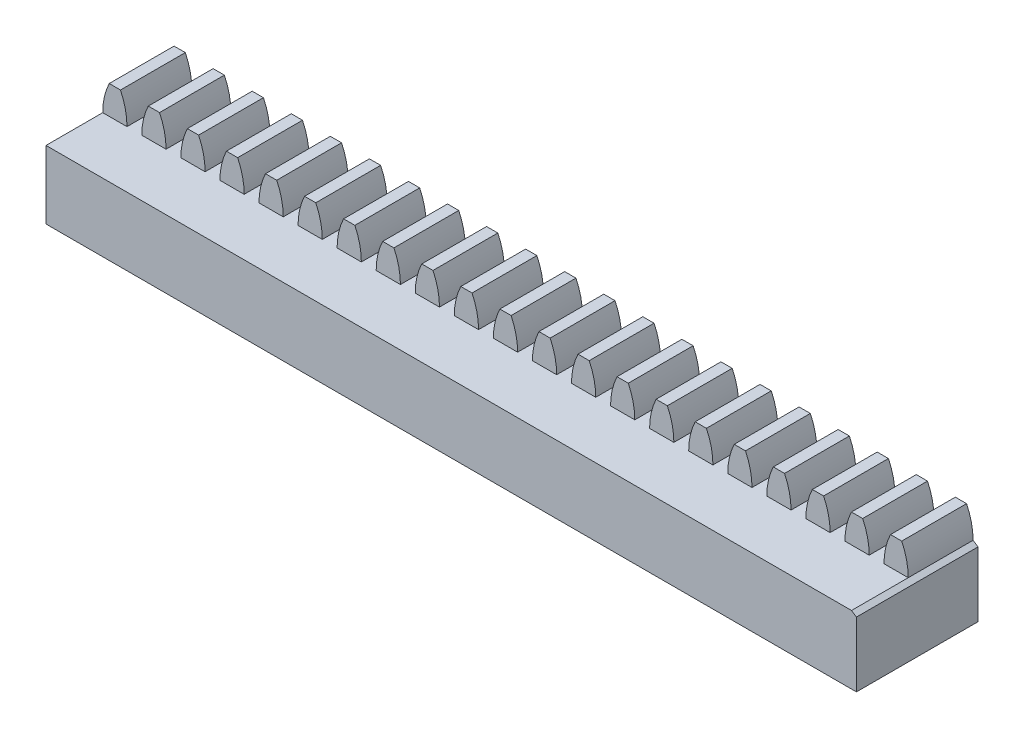
from build123d import *

# Parameters (mm, degrees)
RESSALTO_EXTRUS_O1_DEPTH      = 2
RESSALTO_EXTRUS_O1_2_DEPTH    = 2
RESSALTO_EXTRUS_O1_3_DEPTH    = 2
RESSALTO_EXTRUS_O1_4_DEPTH    = 2
RESSALTO_EXTRUS_O1_5_DEPTH    = 2
RESSALTO_EXTRUS_O1_6_DEPTH    = 2
RESSALTO_EXTRUS_O1_7_DEPTH    = 2
RESSALTO_EXTRUS_O1_8_DEPTH    = 2
RESSALTO_EXTRUS_O1_9_DEPTH    = 2
RESSALTO_EXTRUS_O1_10_DEPTH   = 2
RESSALTO_EXTRUS_O1_11_DEPTH   = 2
RESSALTO_EXTRUS_O1_12_DEPTH   = 2
RESSALTO_EXTRUS_O1_13_DEPTH   = 2
RESSALTO_EXTRUS_O1_14_DEPTH   = 2
RESSALTO_EXTRUS_O1_15_DEPTH   = 2
RESSALTO_EXTRUS_O1_16_DEPTH   = 2
RESSALTO_EXTRUS_O1_17_DEPTH   = 2
RESSALTO_EXTRUS_O1_18_DEPTH   = 2
RESSALTO_EXTRUS_O1_19_DEPTH   = 2
RESSALTO_EXTRUS_O1_20_DEPTH   = 2
RESSALTO_EXTRUS_O1_21_DEPTH   = 2
RESSALTO_EXTRUS_O2_DEPTH      = 5.5
RESSALTO_EXTRUS_O2_DEPTH_BACK = 2


with BuildPart() as part:
    # Esboço1 → Ressalto-extrusão1 (new, symmetric)
    with BuildSketch(Plane.XY):
        with BuildLine():
            Line((-1.017526261, 4.529689969), (-1.711247382, 4.529689969))
            ThreePointArc((-1.711247382, 4.529689969), (-2.010696446, 3.673045524), (-2.112202188, 2.771266155))
            Line((-2.112202188, 2.771266155), (-0.616571456, 2.771266155))
            ThreePointArc((-0.616571456, 2.771266155), (-0.718077198, 3.673045524), (-1.017526261, 4.529689969))
        make_face()
    extrude(amount=RESSALTO_EXTRUS_O1_DEPTH, both=True)



with BuildPart() as body_2:
    # Esboço1 → Ressalto-extrus_o1 2 (new, symmetric)
    with BuildSketch(Plane.XY):
        with BuildLine():
            ThreePointArc((0.698752618, 4.529689969), (0.399303554, 3.673045524), (0.297797812, 2.771266155))
            Line((0.297797812, 2.771266155), (1.793428544, 2.771266155))
            ThreePointArc((1.793428544, 2.771266155), (1.691922802, 3.673045524), (1.392473739, 4.529689969))
            Line((1.392473739, 4.529689969), (0.698752618, 4.529689969))
        make_face()
    extrude(amount=RESSALTO_EXTRUS_O1_2_DEPTH, both=True)


with BuildPart() as body_3:
    # Esboço1 → Ressalto-extrus_o1 3 (new, symmetric)
    with BuildSketch(Plane.XY):
        with BuildLine():
            ThreePointArc((3.108752618, 4.529689969), (2.809303554, 3.673045524), (2.707797812, 2.771266155))
            Line((2.707797812, 2.771266155), (4.203428544, 2.771266155))
            ThreePointArc((4.203428544, 2.771266155), (4.101922802, 3.673045524), (3.802473739, 4.529689969))
            Line((3.802473739, 4.529689969), (3.108752618, 4.529689969))
        make_face()
    extrude(amount=RESSALTO_EXTRUS_O1_3_DEPTH, both=True)


with BuildPart() as body_4:
    # Esboço1 → Ressalto-extrus_o1 4 (new, symmetric)
    with BuildSketch(Plane.XY):
        with BuildLine():
            Line((46.087797812, 2.771266155), (47.583428544, 2.771266155))
            ThreePointArc((47.583428544, 2.771266155), (47.481922802, 3.673045524), (47.182473739, 4.529689969))
            Line((47.182473739, 4.529689969), (46.488752618, 4.529689969))
            ThreePointArc((46.488752618, 4.529689969), (46.189303554, 3.673045524), (46.087797812, 2.771266155))
        make_face()
    extrude(amount=RESSALTO_EXTRUS_O1_4_DEPTH, both=True)


with BuildPart() as body_5:
    # Esboço1 → Ressalto-extrus_o1 5 (new, symmetric)
    with BuildSketch(Plane.XY):
        with BuildLine():
            ThreePointArc((5.518752618, 4.529689969), (5.219303554, 3.673045524), (5.117797812, 2.771266155))
            Line((5.117797812, 2.771266155), (6.613428544, 2.771266155))
            ThreePointArc((6.613428544, 2.771266155), (6.511922802, 3.673045524), (6.212473739, 4.529689969))
            Line((6.212473739, 4.529689969), (5.518752618, 4.529689969))
        make_face()
    extrude(amount=RESSALTO_EXTRUS_O1_5_DEPTH, both=True)


with BuildPart() as body_6:
    # Esboço1 → Ressalto-extrus_o1 6 (new, symmetric)
    with BuildSketch(Plane.XY):
        with BuildLine():
            Line((43.677797812, 2.771266155), (45.173428544, 2.771266155))
            ThreePointArc((45.173428544, 2.771266155), (45.071922802, 3.673045524), (44.772473739, 4.529689969))
            Line((44.772473739, 4.529689969), (44.078752618, 4.529689969))
            ThreePointArc((44.078752618, 4.529689969), (43.779303554, 3.673045524), (43.677797812, 2.771266155))
        make_face()
    extrude(amount=RESSALTO_EXTRUS_O1_6_DEPTH, both=True)


with BuildPart() as body_7:
    # Esboço1 → Ressalto-extrus_o1 7 (new, symmetric)
    with BuildSketch(Plane.XY):
        with BuildLine():
            ThreePointArc((7.928752618, 4.529689969), (7.629303554, 3.673045524), (7.527797812, 2.771266155))
            Line((7.527797812, 2.771266155), (9.023428544, 2.771266155))
            ThreePointArc((9.023428544, 2.771266155), (8.921922802, 3.673045524), (8.622473739, 4.529689969))
            Line((8.622473739, 4.529689969), (7.928752618, 4.529689969))
        make_face()
    extrude(amount=RESSALTO_EXTRUS_O1_7_DEPTH, both=True)


with BuildPart() as body_8:
    # Esboço1 → Ressalto-extrus_o1 8 (new, symmetric)
    with BuildSketch(Plane.XY):
        with BuildLine():
            Line((41.267797812, 2.771266155), (42.763428544, 2.771266155))
            ThreePointArc((42.763428544, 2.771266155), (42.661922802, 3.673045524), (42.362473739, 4.529689969))
            Line((42.362473739, 4.529689969), (41.668752618, 4.529689969))
            ThreePointArc((41.668752618, 4.529689969), (41.369303554, 3.673045524), (41.267797812, 2.771266155))
        make_face()
    extrude(amount=RESSALTO_EXTRUS_O1_8_DEPTH, both=True)


with BuildPart() as body_9:
    # Esboço1 → Ressalto-extrus_o1 9 (new, symmetric)
    with BuildSketch(Plane.XY):
        with BuildLine():
            ThreePointArc((10.338752618, 4.529689969), (10.039303554, 3.673045524), (9.937797812, 2.771266155))
            Line((9.937797812, 2.771266155), (11.433428544, 2.771266155))
            ThreePointArc((11.433428544, 2.771266155), (11.331922802, 3.673045524), (11.032473739, 4.529689969))
            Line((11.032473739, 4.529689969), (10.338752618, 4.529689969))
        make_face()
    extrude(amount=RESSALTO_EXTRUS_O1_9_DEPTH, both=True)


with BuildPart() as body_10:
    # Esboço1 → Ressalto-extrus_o1 10 (new, symmetric)
    with BuildSketch(Plane.XY):
        with BuildLine():
            Line((38.857797812, 2.771266155), (40.353428544, 2.771266155))
            ThreePointArc((40.353428544, 2.771266155), (40.251922802, 3.673045524), (39.952473739, 4.529689969))
            Line((39.952473739, 4.529689969), (39.258752618, 4.529689969))
            ThreePointArc((39.258752618, 4.529689969), (38.959303554, 3.673045524), (38.857797812, 2.771266155))
        make_face()
    extrude(amount=RESSALTO_EXTRUS_O1_10_DEPTH, both=True)


with BuildPart() as body_11:
    # Esboço1 → Ressalto-extrus_o1 11 (new, symmetric)
    with BuildSketch(Plane.XY):
        with BuildLine():
            ThreePointArc((12.748752618, 4.529689969), (12.449303554, 3.673045524), (12.347797812, 2.771266155))
            Line((12.347797812, 2.771266155), (13.843428544, 2.771266155))
            ThreePointArc((13.843428544, 2.771266155), (13.741922802, 3.673045524), (13.442473739, 4.529689969))
            Line((13.442473739, 4.529689969), (12.748752618, 4.529689969))
        make_face()
    extrude(amount=RESSALTO_EXTRUS_O1_11_DEPTH, both=True)


with BuildPart() as body_12:
    # Esboço1 → Ressalto-extrus_o1 12 (new, symmetric)
    with BuildSketch(Plane.XY):
        with BuildLine():
            Line((36.447797812, 2.771266155), (37.943428544, 2.771266155))
            ThreePointArc((37.943428544, 2.771266155), (37.841922802, 3.673045524), (37.542473739, 4.529689969))
            Line((37.542473739, 4.529689969), (36.848752618, 4.529689969))
            ThreePointArc((36.848752618, 4.529689969), (36.549303554, 3.673045524), (36.447797812, 2.771266155))
        make_face()
    extrude(amount=RESSALTO_EXTRUS_O1_12_DEPTH, both=True)


with BuildPart() as body_13:
    # Esboço1 → Ressalto-extrus_o1 13 (new, symmetric)
    with BuildSketch(Plane.XY):
        with BuildLine():
            ThreePointArc((15.158752618, 4.529689969), (14.859303554, 3.673045524), (14.757797812, 2.771266155))
            Line((14.757797812, 2.771266155), (16.253428544, 2.771266155))
            ThreePointArc((16.253428544, 2.771266155), (16.151922802, 3.673045524), (15.852473739, 4.529689969))
            Line((15.852473739, 4.529689969), (15.158752618, 4.529689969))
        make_face()
    extrude(amount=RESSALTO_EXTRUS_O1_13_DEPTH, both=True)


with BuildPart() as body_14:
    # Esboço1 → Ressalto-extrus_o1 14 (new, symmetric)
    with BuildSketch(Plane.XY):
        with BuildLine():
            Line((34.037797812, 2.771266155), (35.533428544, 2.771266155))
            ThreePointArc((35.533428544, 2.771266155), (35.431922802, 3.673045524), (35.132473739, 4.529689969))
            Line((35.132473739, 4.529689969), (34.438752618, 4.529689969))
            ThreePointArc((34.438752618, 4.529689969), (34.139303554, 3.673045524), (34.037797812, 2.771266155))
        make_face()
    extrude(amount=RESSALTO_EXTRUS_O1_14_DEPTH, both=True)


with BuildPart() as body_15:
    # Esboço1 → Ressalto-extrus_o1 15 (new, symmetric)
    with BuildSketch(Plane.XY):
        with BuildLine():
            ThreePointArc((17.568752618, 4.529689969), (17.269303554, 3.673045524), (17.167797812, 2.771266155))
            Line((17.167797812, 2.771266155), (18.663428544, 2.771266155))
            ThreePointArc((18.663428544, 2.771266155), (18.561922802, 3.673045524), (18.262473739, 4.529689969))
            Line((18.262473739, 4.529689969), (17.568752618, 4.529689969))
        make_face()
    extrude(amount=RESSALTO_EXTRUS_O1_15_DEPTH, both=True)


with BuildPart() as body_16:
    # Esboço1 → Ressalto-extrus_o1 16 (new, symmetric)
    with BuildSketch(Plane.XY):
        with BuildLine():
            Line((31.627797812, 2.771266155), (33.123428544, 2.771266155))
            ThreePointArc((33.123428544, 2.771266155), (33.021922802, 3.673045524), (32.722473739, 4.529689969))
            Line((32.722473739, 4.529689969), (32.028752618, 4.529689969))
            ThreePointArc((32.028752618, 4.529689969), (31.729303554, 3.673045524), (31.627797812, 2.771266155))
        make_face()
    extrude(amount=RESSALTO_EXTRUS_O1_16_DEPTH, both=True)


with BuildPart() as body_17:
    # Esboço1 → Ressalto-extrus_o1 17 (new, symmetric)
    with BuildSketch(Plane.XY):
        with BuildLine():
            ThreePointArc((19.978752618, 4.529689969), (19.679303554, 3.673045524), (19.577797812, 2.771266155))
            Line((19.577797812, 2.771266155), (21.073428544, 2.771266155))
            ThreePointArc((21.073428544, 2.771266155), (20.971922802, 3.673045524), (20.672473739, 4.529689969))
            Line((20.672473739, 4.529689969), (19.978752618, 4.529689969))
        make_face()
    extrude(amount=RESSALTO_EXTRUS_O1_17_DEPTH, both=True)


with BuildPart() as body_18:
    # Esboço1 → Ressalto-extrus_o1 18 (new, symmetric)
    with BuildSketch(Plane.XY):
        with BuildLine():
            Line((29.217797812, 2.771266155), (30.713428544, 2.771266155))
            ThreePointArc((30.713428544, 2.771266155), (30.611922802, 3.673045524), (30.312473739, 4.529689969))
            Line((30.312473739, 4.529689969), (29.618752618, 4.529689969))
            ThreePointArc((29.618752618, 4.529689969), (29.319303554, 3.673045524), (29.217797812, 2.771266155))
        make_face()
    extrude(amount=RESSALTO_EXTRUS_O1_18_DEPTH, both=True)


with BuildPart() as body_19:
    # Esboço1 → Ressalto-extrus_o1 19 (new, symmetric)
    with BuildSketch(Plane.XY):
        with BuildLine():
            ThreePointArc((22.388752618, 4.529689969), (22.089303554, 3.673045524), (21.987797812, 2.771266155))
            Line((21.987797812, 2.771266155), (23.483428544, 2.771266155))
            ThreePointArc((23.483428544, 2.771266155), (23.381922802, 3.673045524), (23.082473739, 4.529689969))
            Line((23.082473739, 4.529689969), (22.388752618, 4.529689969))
        make_face()
    extrude(amount=RESSALTO_EXTRUS_O1_19_DEPTH, both=True)


with BuildPart() as body_20:
    # Esboço1 → Ressalto-extrus_o1 20 (new, symmetric)
    with BuildSketch(Plane.XY):
        with BuildLine():
            Line((26.807797812, 2.771266155), (28.303428544, 2.771266155))
            ThreePointArc((28.303428544, 2.771266155), (28.201922802, 3.673045524), (27.902473739, 4.529689969))
            Line((27.902473739, 4.529689969), (27.208752618, 4.529689969))
            ThreePointArc((27.208752618, 4.529689969), (26.909303554, 3.673045524), (26.807797812, 2.771266155))
        make_face()
    extrude(amount=RESSALTO_EXTRUS_O1_20_DEPTH, both=True)


with BuildPart() as body_21:
    # Esboço1 → Ressalto-extrus_o1 21 (new, symmetric)
    with BuildSketch(Plane.XY):
        with BuildLine():
            ThreePointArc((24.798752618, 4.529689969), (24.499303554, 3.673045524), (24.397797812, 2.771266155))
            Line((24.397797812, 2.771266155), (25.893428544, 2.771266155))
            ThreePointArc((25.893428544, 2.771266155), (25.791922802, 3.673045524), (25.492473739, 4.529689969))
            Line((25.492473739, 4.529689969), (24.798752618, 4.529689969))
        make_face()
    extrude(amount=RESSALTO_EXTRUS_O1_21_DEPTH, both=True)


with BuildPart() as part_1:
    add(part.part)

    add(body_2.part)  # Ressalto-extrusão2 merges body 2

    add(body_3.part)  # Ressalto-extrusão2 merges body 3

    add(body_4.part)  # Ressalto-extrusão2 merges body 4

    add(body_5.part)  # Ressalto-extrusão2 merges body 5

    add(body_6.part)  # Ressalto-extrusão2 merges body 6

    add(body_7.part)  # Ressalto-extrusão2 merges body 7

    add(body_8.part)  # Ressalto-extrusão2 merges body 8

    add(body_9.part)  # Ressalto-extrusão2 merges body 9

    add(body_10.part)  # Ressalto-extrusão2 merges body 10

    add(body_11.part)  # Ressalto-extrusão2 merges body 11

    add(body_12.part)  # Ressalto-extrusão2 merges body 12

    add(body_13.part)  # Ressalto-extrusão2 merges body 13

    add(body_14.part)  # Ressalto-extrusão2 merges body 14

    add(body_15.part)  # Ressalto-extrusão2 merges body 15

    add(body_16.part)  # Ressalto-extrusão2 merges body 16

    add(body_17.part)  # Ressalto-extrusão2 merges body 17

    add(body_18.part)  # Ressalto-extrusão2 merges body 18

    add(body_19.part)  # Ressalto-extrusão2 merges body 19

    add(body_20.part)  # Ressalto-extrusão2 merges body 20

    add(body_21.part)  # Ressalto-extrusão2 merges body 21
    # Esboço1<7> → Ressalto-extrusão2 (add, two sides: drawn at the far end of the back side and taken through both)
    with BuildSketch(Plane.XY.offset(-RESSALTO_EXTRUS_O2_DEPTH_BACK)):
        Polygon((-0.616571456, 2.771266155), (-2.112202188, 2.771266155), (-2.112202188, -1.428733845), (47.887797812, -1.428733845), (47.887797812, 2.571294167), (47.583428544, 2.771266155), (46.087797812, 2.771266155), (45.173428544, 2.771266155), (43.677797812, 2.771266155), (42.763428544, 2.771266155), (41.267797812, 2.771266155), (40.353428544, 2.771266155), (38.857797812, 2.771266155), (37.943428544, 2.771266155), (36.447797812, 2.771266155), (35.533428544, 2.771266155), (34.037797812, 2.771266155), (33.123428544, 2.771266155), (31.627797812, 2.771266155), (30.713428544, 2.771266155), (29.217797812, 2.771266155), (28.303428544, 2.771266155), (26.807797812, 2.771266155), (25.893428544, 2.771266155), (24.397797812, 2.771266155), (23.483428544, 2.771266155), (21.987797812, 2.771266155), (21.073428544, 2.771266155), (19.577797812, 2.771266155), (18.663428544, 2.771266155), (17.167797812, 2.771266155), (16.253428544, 2.771266155), (14.757797812, 2.771266155), (13.843428544, 2.771266155), (12.347797812, 2.771266155), (11.433428544, 2.771266155), (9.937797812, 2.771266155), (9.023428544, 2.771266155), (7.527797812, 2.771266155), (6.613428544, 2.771266155), (5.117797812, 2.771266155), (4.203428544, 2.771266155), (2.707797812, 2.771266155), (1.793428544, 2.771266155), (0.297797812, 2.771266155), align=None)
    extrude(amount=RESSALTO_EXTRUS_O2_DEPTH + RESSALTO_EXTRUS_O2_DEPTH_BACK)


solid = part_1.part
